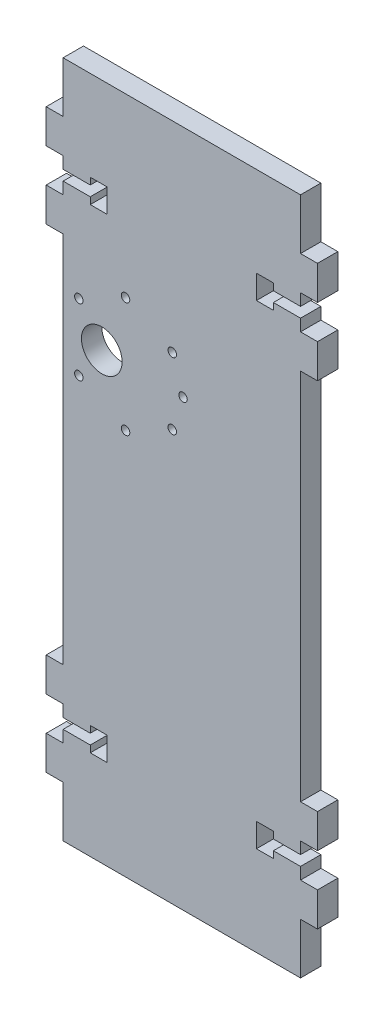
from build123d import *

# Parameters (mm, degrees)
MODEL_R                  = 1.25
MODEL_R_2                = 6
RESSALTO_EXTRUS_O1_DEPTH = 6


with BuildPart() as part:
    # Model → Ressalto-extrusão1 (new body)
    with BuildSketch(Plane.XY):
        Polygon((70, -31.5), (62, -31.5), (62, -33.5), (57, -33.5), (57, -26.5), (62, -26.5), (62, -28.5), (70, -28.5), (70, -25), (75, -25), (75, -15), (70, -15), (70, 0), (0, 0), (0, -15), (-5, -15), (-5, -25), (0, -25), (0, -28.5), (8, -28.5), (8, -26.5), (13, -26.5), (13, -33.5), (8, -33.5), (8, -31.5), (0, -31.5), (0, -35), (-5, -35), (-5, -45), (0, -45), (0, -155), (-5, -155), (-5, -165), (0, -165), (0, -168.5), (8, -168.5), (8, -166.5), (13, -166.5), (13, -173.5), (8, -173.5), (8, -171.5), (0, -171.5), (0, -175), (-5, -175), (-5, -185), (0, -185), (0, -200), (70, -200), (70, -185), (75, -185), (75, -175), (70, -175), (70, -171.5), (62, -171.5), (62, -173.5), (57, -173.5), (57, -166.5), (62, -166.5), (62, -168.5), (70, -168.5), (70, -165), (75, -165), (75, -155), (70, -155), (70, -45), (75, -45), (75, -35), (70, -35), align=None)
        with Locations((32.177, -78.842)):
            Circle(MODEL_R, mode=Mode.SUBTRACT)
        with Locations((35.353, -69)):
            Circle(MODEL_R, mode=Mode.SUBTRACT)
        with Locations((32.177, -59.158)):
            Circle(MODEL_R, mode=Mode.SUBTRACT)
        with Locations((18.403, -52.05)):
            Circle(MODEL_R, mode=Mode.SUBTRACT)
        with Locations((4.629, -59.158)):
            Circle(MODEL_R, mode=Mode.SUBTRACT)
        with Locations((4.629, -78.842)):
            Circle(MODEL_R, mode=Mode.SUBTRACT)
        with Locations((18.403, -85.95)):
            Circle(MODEL_R, mode=Mode.SUBTRACT)
        with Locations((11.4, -69)):
            Circle(MODEL_R_2, mode=Mode.SUBTRACT)
    extrude(amount=RESSALTO_EXTRUS_O1_DEPTH)


solid = part.part
